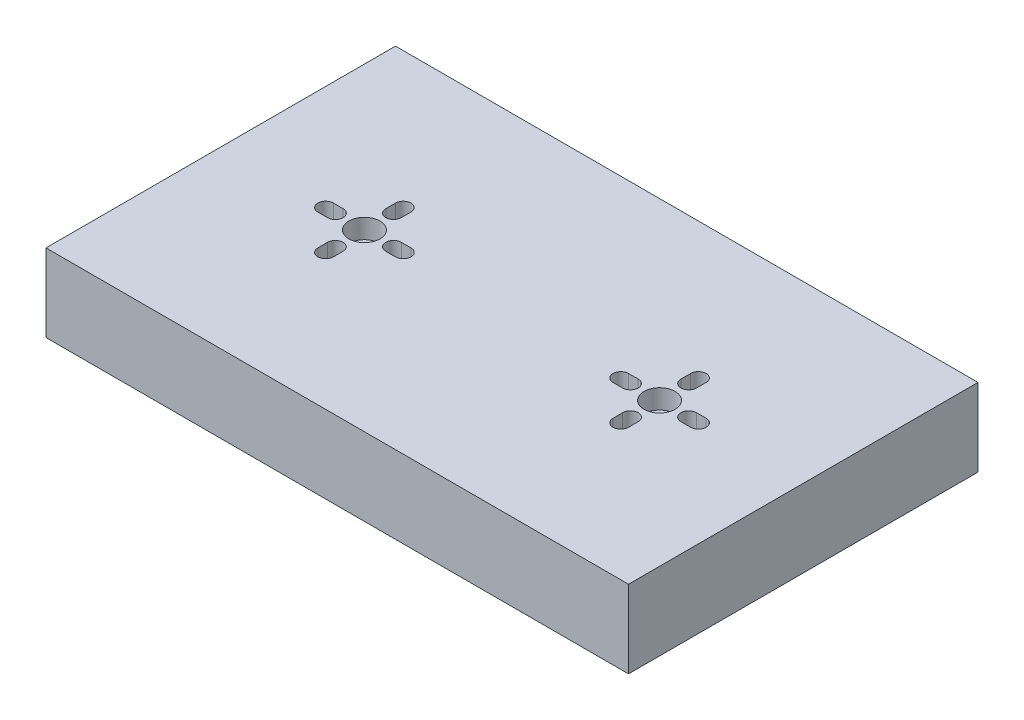
from build123d import *

# Parameters (mm, degrees)
SKETCH2_W           = 150
SKETCH2_H           = 90
BOSS_EXTRUDE1_DEPTH = 20
SKETCH3_R           = 4
CUT_EXTRUDE1_DEPTH  = 5
CUT_EXTRUDE2_DEPTH  = 21


with BuildPart() as part:
    # Sketch2 → Boss-Extrude1 (new body)
    with BuildSketch(Plane(origin=(0, 0, 0), x_dir=(1, 0, 0), z_dir=(0, 1, 0))):
        Rectangle(SKETCH2_W, SKETCH2_H)
    extrude(amount=BOSS_EXTRUDE1_DEPTH)

    # Sketch3 → Cut-Extrude1 (cut)
    with BuildSketch(Plane(origin=(0, 20, 0), x_dir=(1, 0, 0), z_dir=(0, 1, 0))):
        with Locations((-38, 0)):
            Circle(SKETCH3_R)
        with Locations((38, 0)):
            Circle(SKETCH3_R)
    extrude(amount=-CUT_EXTRUDE1_DEPTH, mode=Mode.SUBTRACT)

    # Sketch4 → Cut-Extrude2 (cut, through all)
    with BuildSketch(Plane(origin=(0, 20, 0), x_dir=(1, 0, 0), z_dir=(0, 1, 0))):
        with BuildLine():
            Line((-45.5, 2.006446443), (-48, 2.006446443))
            ThreePointArc((-48, 2.006446443), (-50.006446443, 0), (-48, -2.006446443))
            Line((-48, -2.006446443), (-45.5, -2.006446443))
            ThreePointArc((-45.5, -2.006446443), (-43.493553557, 0), (-45.5, 2.006446443))
        make_face()
        with BuildLine():
            Line((-36, 7.5), (-36, 10))
            ThreePointArc((-36, 10), (-38, 12), (-40, 10))
            Line((-40, 10), (-40, 7.5))
            ThreePointArc((-40, 7.5), (-38, 5.5), (-36, 7.5))
        make_face()
        with BuildLine():
            Line((-28, 2), (-30.5, 2))
            ThreePointArc((-30.5, 2), (-32.5, 0), (-30.5, -2))
            Line((-30.5, -2), (-28, -2))
            ThreePointArc((-28, -2), (-26, 0), (-28, 2))
        make_face()
        with BuildLine():
            Line((-40, -7.5), (-40, -10))
            ThreePointArc((-40, -10), (-38, -12), (-36, -10))
            Line((-36, -10), (-36, -7.5))
            ThreePointArc((-36, -7.5), (-38, -5.5), (-40, -7.5))
        make_face()
        with BuildLine():
            ThreePointArc((48, -2.006446443), (50.006446443, 0), (48, 2.006446443))
            Line((48, 2.006446443), (45.5, 2.006446443))
            ThreePointArc((45.5, 2.006446443), (43.493553557, 0), (45.5, -2.006446443))
            Line((45.5, -2.006446443), (48, -2.006446443))
        make_face()
        with BuildLine():
            ThreePointArc((40, 10), (38, 12), (36, 10))
            Line((36, 10), (36, 7.5))
            ThreePointArc((36, 7.5), (38, 5.5), (40, 7.5))
            Line((40, 7.5), (40, 10))
        make_face()
        with BuildLine():
            ThreePointArc((30.5, -2), (32.5, 0), (30.5, 2))
            Line((30.5, 2), (28, 2))
            ThreePointArc((28, 2), (26, 0), (28, -2))
            Line((28, -2), (30.5, -2))
        make_face()
        with BuildLine():
            ThreePointArc((36, -10), (38, -12), (40, -10))
            Line((40, -10), (40, -7.5))
            ThreePointArc((40, -7.5), (38, -5.5), (36, -7.5))
            Line((36, -7.5), (36, -10))
        make_face()
    extrude(amount=-CUT_EXTRUDE2_DEPTH, mode=Mode.SUBTRACT)


solid = part.part
